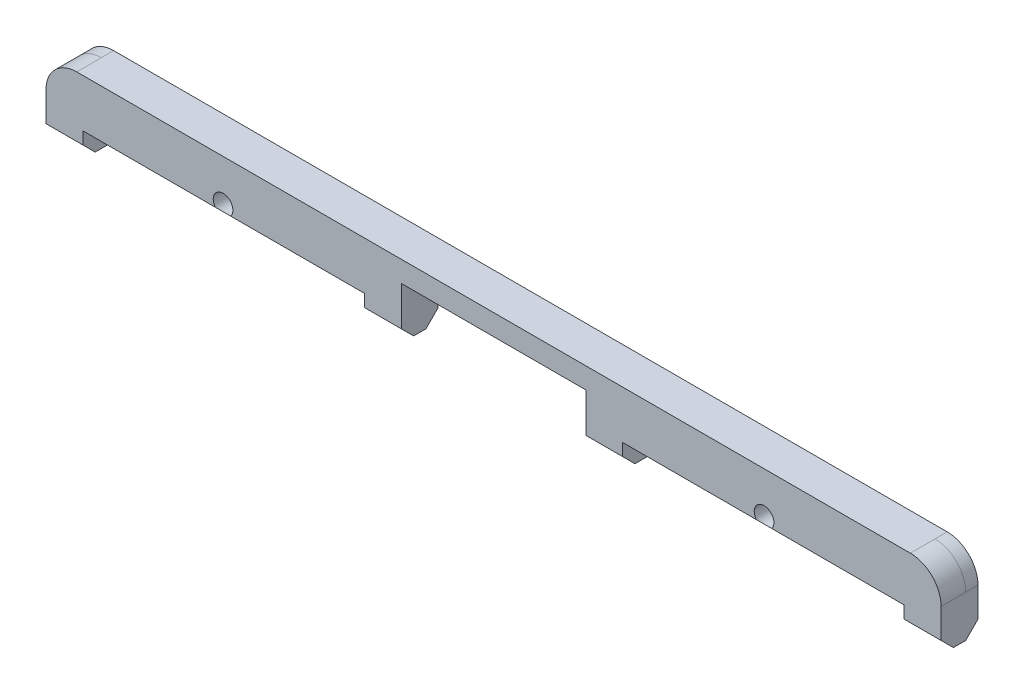
from build123d import *

# Parameters (mm, degrees)
BOSS_EXTRUDE1_DEPTH       = 36.4
FILLET3_R                 = 2.5
CUT_EXTRUDE5_DEPTH        = 72.8
BOSS_EXTRUDE2_DEPTH       = 72.8
M2X0_4_TAPPED_HOLE1_D     = 1.6
M2X0_4_TAPPED_HOLE1_DEPTH = 3.6
M2X0_4_TAPPED_HOLE1_TIP   = 0.480688495
FILLET4_R                 = 2.5
SKETCH4_W                 = 15
SKETCH4_H                 = 4.7
CUT_EXTRUDE4_DEPTH        = 5
BOSS_EXTRUDE6_DEPTH       = 3
BOSS_EXTRUDE7_DEPTH       = 3


with BuildPart() as part:
    # Sketch1 → Boss-Extrude1 (new body, symmetric)
    with BuildSketch(Plane(origin=(0, 0, 0), x_dir=(0, 0, -1), z_dir=(1, 0, 0))):
        Polygon((0, -3.2), (-2, -1.2), (-2, 3.2), (0, 3.2), align=None)
    extrude(amount=BOSS_EXTRUDE1_DEPTH, both=True)

    # Fillet3
    fillet3_edges = [part.edges().sort_by_distance(p)[0] for p in [
        (-36.4, 3.2, 1),
        (36.4, 3.2, 1),
    ]]
    fillet(fillet3_edges, radius=FILLET3_R)

    # Sketch5 → Cut-Extrude5 (cut)
    with BuildSketch(Plane.ZY.offset(36.4)):
        Polygon((0, -2.7), (2, -0.7), (2, -1.2), (0, -3.2), align=None)
    extrude(amount=-CUT_EXTRUDE5_DEPTH, mode=Mode.SUBTRACT)

    # Sketch7 → Boss-Extrude2 (add)
    with BuildSketch(Plane.ZY.offset(36.4)):
        Polygon((0, -2.7), (-1, -1.7), (-1, 3.2), (0, 3.2), align=None)
    extrude(amount=-BOSS_EXTRUDE2_DEPTH)

    # M2x0.4 Tapped Hole1
    with Locations(Plane.XY.offset(2)):
        with Locations((-22, -0.2), (22, -0.2), (0, -0.2)):
            Hole(M2X0_4_TAPPED_HOLE1_D / 2, depth=M2X0_4_TAPPED_HOLE1_DEPTH)
            with Locations((0, 0, -(M2X0_4_TAPPED_HOLE1_DEPTH + M2X0_4_TAPPED_HOLE1_TIP / 2))):  # 118° drill point
                Cone(0, M2X0_4_TAPPED_HOLE1_D / 2, M2X0_4_TAPPED_HOLE1_TIP, mode=Mode.SUBTRACT)

    # Fillet4
    fillet4_edges = [part.edges().sort_by_distance(p)[0] for p in [
        (36.4, 3.2, -0.5),
        (-36.4, 3.2, -0.5),
    ]]
    fillet(fillet4_edges, radius=FILLET4_R)

    # Sketch4 → Cut-Extrude4 (cut, symmetric)
    with BuildSketch(Plane.XY):
        with Locations((0, -0.85)):
            Rectangle(SKETCH4_W, SKETCH4_H)
    extrude(amount=CUT_EXTRUDE4_DEPTH, both=True, mode=Mode.SUBTRACT)

    # Sketch11 → Boss-Extrude6 (add)
    with BuildSketch(Plane(origin=(36.4, 0, 0), x_dir=(0, 0, -1), z_dir=(1, 0, 0))):
        Polygon((0, -2.7), (-1, -2.7), (-2, -1.7), (-2, -0.7), align=None)
    extrude(amount=-BOSS_EXTRUDE6_DEPTH)

    # Sketch12 → Boss-Extrude7 (add)
    with BuildSketch(Plane.ZY.offset(-7.5)):
        Polygon((0, -2.7), (1, -2.7), (2, -1.7), (2, -0.7), align=None)
    extrude(amount=-BOSS_EXTRUDE7_DEPTH)

    # Mirror7: part across plane


with BuildPart() as part_1:
    add(part.part)
    add(part.part.mirror(Plane(origin=(0, 0, 0), x_dir=(0, 0, 1), z_dir=(1, 0, 0))))


solid = part_1.part
